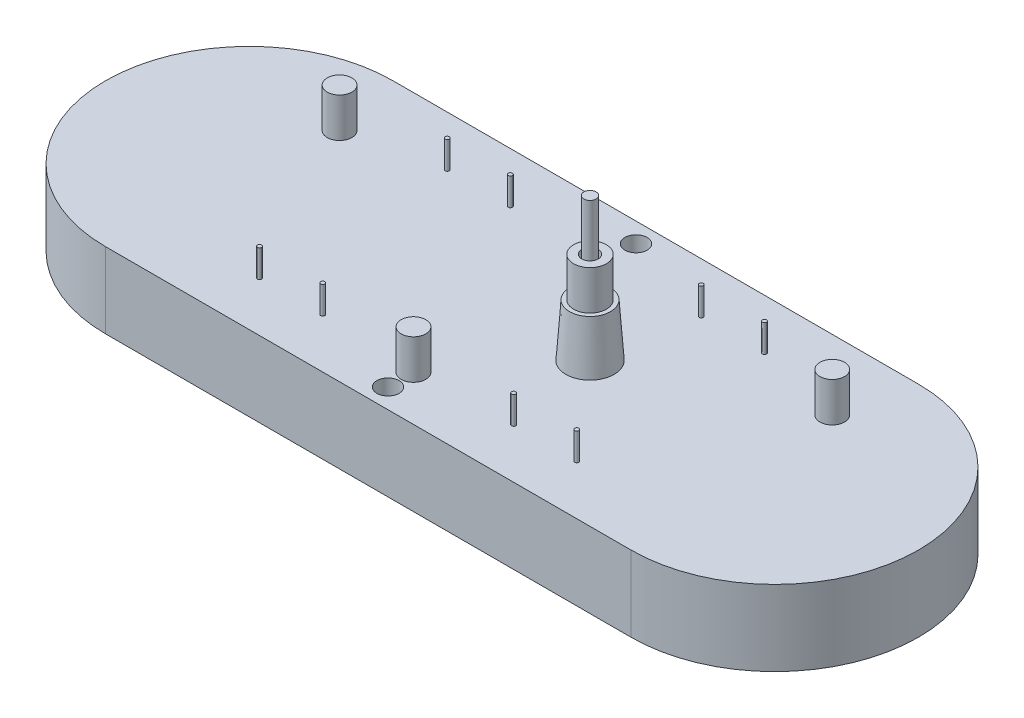
from build123d import *

# Parameters (mm, degrees)
BOSS_EXTRUDE1_DEPTH = 9.2
SKETCH2_W           = 0.75
SKETCH2_H           = 17.4
SKETCH3_R           = 1.5
BOSS_EXTRUDE2_DEPTH = 4.8
SKETCH4_R           = 0.25
BOSS_EXTRUDE3_DEPTH = 3.35
SKETCH5_R           = 1.35
CUT_EXTRUDE1_DEPTH  = 10.2


with BuildPart() as part:
    # Sketch1 → Boss-Extrude1 (new body)
    with BuildSketch(Plane(origin=(0, 0, 0), x_dir=(1, 0, 0), z_dir=(0, 1, 0))):
        with BuildLine():
            Line((-32, 17.5), (32, 17.5))
            ThreePointArc((32, 17.5), (49.5, 0), (32, -17.5))
            Line((32, -17.5), (-32, -17.5))
            ThreePointArc((-32, -17.5), (-49.5, 0), (-32, 17.5))
        make_face()
    extrude(amount=-BOSS_EXTRUDE1_DEPTH)

    # Sketch2 → Revolve1 (revolve)
    with BuildSketch(Plane(origin=(9.5, 0, 0), x_dir=(0, 0, -1), z_dir=(1, 0, 0))):
        with Locations((0.375, 8.7)):
            Rectangle(SKETCH2_W, SKETCH2_H)
        Polygon((1, 0), (2.947531596, 0), (2.5, 6.4), (2, 6.4), (2, 11.2), (1, 11.2), align=None)
    revolve(axis=Axis((9.5, 0, 0), (0, 1, 0)))

    # Sketch3 → Boss-Extrude2 (add)
    with BuildSketch(Plane(origin=(0, 0, 0), x_dir=(1, 0, 0), z_dir=(0, 1, 0))):
        with Locations((0, -12)):
            Circle(SKETCH3_R)
        with Locations((30, 9)):
            Circle(SKETCH3_R)
        with Locations((-30, 9)):
            Circle(SKETCH3_R)
    extrude(amount=BOSS_EXTRUDE2_DEPTH)

    # Sketch4 → Boss-Extrude3 (add)
    with BuildSketch(Plane(origin=(0, 0, 0), x_dir=(1, 0, 0), z_dir=(0, 1, 0))):
        with Locations((-19.32, 11.425)):
            Circle(SKETCH4_R)
        with Locations((-11.62, 11.425)):
            Circle(SKETCH4_R)
        with Locations((-11.62, -11.425)):
            Circle(SKETCH4_R)
        with Locations((-19.32, -11.425)):
            Circle(SKETCH4_R)
        with Locations((19.32, -11.425)):
            Circle(SKETCH4_R)
        with Locations((11.62, -11.425)):
            Circle(SKETCH4_R)
        with Locations((11.62, 11.425)):
            Circle(SKETCH4_R)
        with Locations((19.32, 11.425)):
            Circle(SKETCH4_R)
    extrude(amount=BOSS_EXTRUDE3_DEPTH)

    # Sketch5 → Cut-Extrude1 (cut, through all)
    with BuildSketch(Plane(origin=(0, 0, 0), x_dir=(1, 0, 0), z_dir=(0, 1, 0))):
        with Locations((0, 15.1)):
            Circle(SKETCH5_R)
        with Locations((0, -15.1)):
            Circle(SKETCH5_R)
    extrude(amount=-CUT_EXTRUDE1_DEPTH, mode=Mode.SUBTRACT)


solid = part.part
